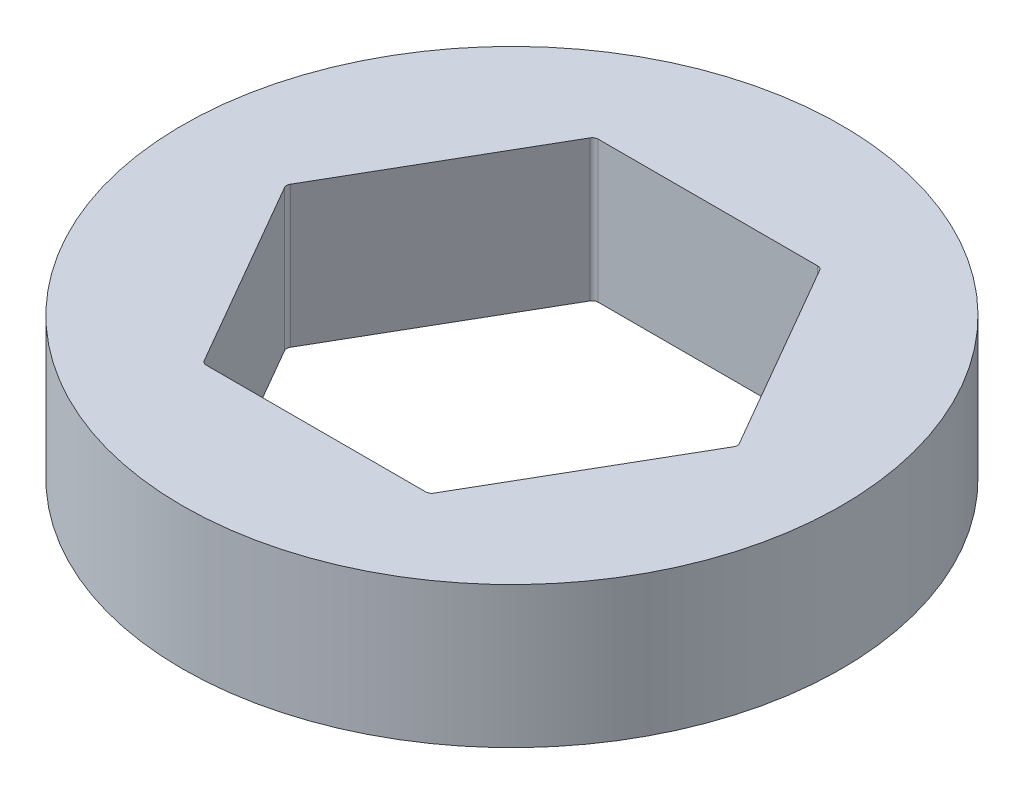
from build123d import *

# Parameters (mm, degrees)
SKETCH1_R           = 11.1125
BOSS_EXTRUDE1_DEPTH = 4.7625
FILLET1_R           = 0.2


with BuildPart() as part:
    # Sketch1 → Boss-Extrude1 (new body)
    with BuildSketch(Plane(origin=(0, 0, 0), x_dir=(1, 0, 0), z_dir=(0, 1, 0))):
        Circle(SKETCH1_R)
        Polygon((7.625642355, 0), (3.812821178, 6.604), (-3.812821178, 6.604), (-7.625642355, 0), (-3.812821178, -6.604), (3.812821178, -6.604), align=None, mode=Mode.SUBTRACT)
    extrude(amount=BOSS_EXTRUDE1_DEPTH)

    # Fillet1
    fillet1_edges = [part.edges().sort_by_distance(p)[0] for p in [
        (7.625642355, 2.38125, 0),
        (3.812821178, 2.38125, -6.604),
        (-3.812821178, 2.38125, -6.604),
        (-7.625642355, 2.38125, 0),
        (-3.812821178, 2.38125, 6.604),
        (3.812821178, 2.38125, 6.604),
    ]]
    fillet(fillet1_edges, radius=FILLET1_R)


solid = part.part
